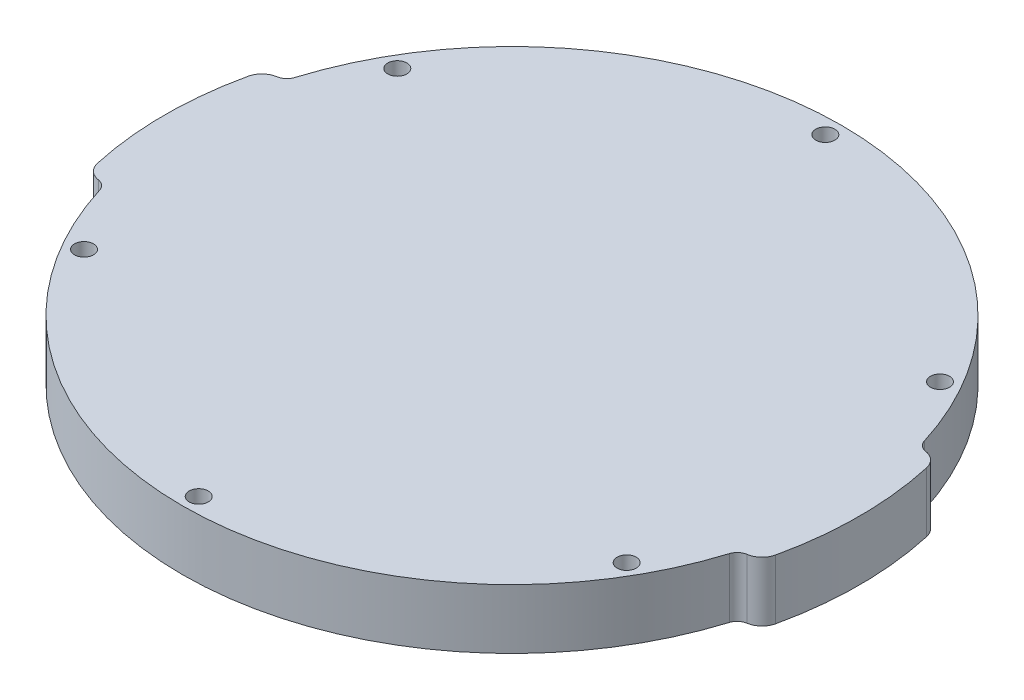
from build123d import *

# Parameters (mm, degrees)
EXTRUDE_1_DEPTH     = 10
FILLET_2_R          = 3
FILLET_3_R          = 2
SKETCH_2_R          = 1.6
CUT_EXTRUDE_1_DEPTH = 11.0000001


with BuildPart() as part:
    # 草图1 → 凸台-拉伸1 (new body)
    with BuildSketch(Plane(origin=(0, 0, 0), x_dir=(1, 0, 0), z_dir=(0, 1, 0))):
        with BuildLine():
            Line((-53.174829572, -15), (-56.285544325, -15))
            ThreePointArc((-56.285544325, -15), (-57.756798115, -7.564044654), (-58.25, 0))
            ThreePointArc((-58.25, 0), (-57.756798115, 7.564044654), (-56.285544325, 15))
            add(Edge.make_bspline(
                [(-56.285544325, 15), (-53.174829572, 15)],
                knots=[0, 0, 1, 1], degree=1))
            ThreePointArc((-53.174829572, 15), (-33.345258284, 44.052880156), (0, 55.25))
            ThreePointArc((0, 55.25), (33.345258284, 44.052880156), (53.174829572, 15))
            Line((53.174829572, 15), (56.285544325, 15))
            ThreePointArc((56.285544325, 15), (57.756798115, 7.564044654), (58.25, 0))
            ThreePointArc((58.25, 0), (57.756798115, -7.564044654), (56.285544325, -15))
            Line((56.285544325, -15), (53.174829572, -15))
            ThreePointArc((53.174829572, -15), (33.345258284, -44.052880156), (0, -55.25))
            ThreePointArc((0, -55.25), (-33.345258284, -44.052880156), (-53.174829572, -15))
        make_face()
    extrude(amount=EXTRUDE_1_DEPTH)

    # 圆角2
    fillet_2_edges = [part.edges().sort_by_distance(p)[0] for p in [
        (-56.285544325, 5, -15),
        (56.285544325, 5, -15),
        (56.285544325, 5, 15),
        (-56.285544325, 5, 15),
    ]]
    fillet(fillet_2_edges, radius=FILLET_2_R)

    # 圆角3
    fillet_3_edges = [part.edges().sort_by_distance(p)[0] for p in [
        (-53.174829572, 5, -15),
        (53.174829572, 5, -15),
        (53.174829572, 5, 15),
        (-53.174829572, 5, 15),
    ]]
    fillet(fillet_3_edges, radius=FILLET_3_R)

    # 草图2 → 切除-拉伸1 (cut, through all)
    with BuildSketch(Plane.XZ):
        with Locations((0, 52.525)):
            Circle(SKETCH_2_R)
        with Locations((45.487984334, 26.2625)):
            Circle(SKETCH_2_R)
        with Locations((45.487984334, -26.2625)):
            Circle(SKETCH_2_R)
        with Locations((0, -52.525)):
            Circle(SKETCH_2_R)
        with Locations((-45.487984334, -26.2625)):
            Circle(SKETCH_2_R)
        with Locations((-45.487984334, 26.2625)):
            Circle(SKETCH_2_R)
    extrude(amount=-CUT_EXTRUDE_1_DEPTH, mode=Mode.SUBTRACT)


solid = part.part
